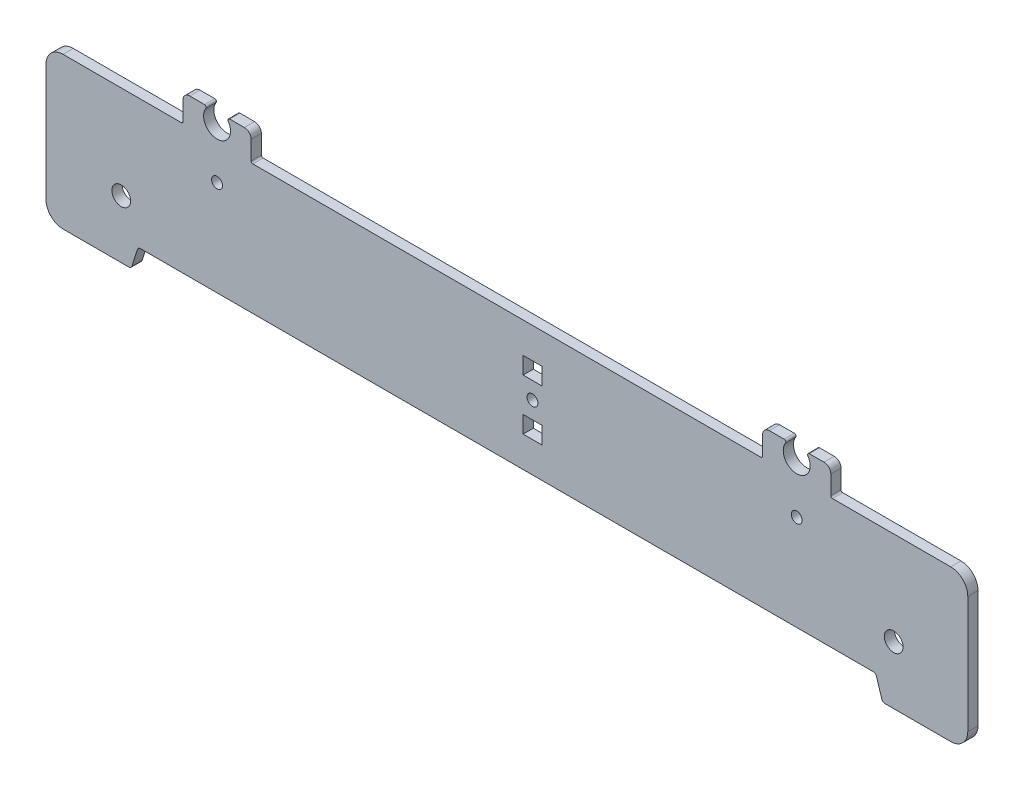
from build123d import *

# Parameters (mm, degrees)
MODEL_R                 = 1.6
MODEL_R_2               = 2.75
MODEL_W                 = 5.5
MODEL_H                 = 5
SALIENTE_EXTRUIR1_DEPTH = 3


with BuildPart() as part:
    # Model → Saliente-Extruir1 (new body)
    with BuildSketch(Plane.XY):
        with BuildLine():
            Line((136.131313967, 8.172644832), (28.691078747, 8.175075185))
            ThreePointArc((28.691078747, 8.175075185), (28.098964944, 7.980929542), (27.736763771, 7.473877674))
            Line((27.736763771, 7.473877674), (26.175859161, 2.488662696))
            ThreePointArc((26.175859161, 2.488662696), (25.813657989, 1.981610828), (25.221544186, 1.787465185))
            Line((25.221544186, 1.787465185), (5.956313823, 1.787465185))
            ThreePointArc((5.956313823, 1.787465185), (2.420778394, 3.251930446), (0.956311467, 6.787465185))
            Line((0.956311467, 6.787465185), (0.956311467, 41.175060185))
            ThreePointArc((0.956311467, 41.175060185), (2.420777561, 44.710594091), (5.956311467, 46.175060185))
            Line((5.956311467, 46.175060185), (10.956311467, 46.175060185))
            Line((10.956311467, 46.175060185), (40.628815467, 46.175060185))
            ThreePointArc((40.628815467, 46.175060185), (40.982368857, 46.321506794), (41.128815467, 46.675060185))
            Line((41.128815467, 46.675060185), (41.128815467, 52.173080185))
            ThreePointArc((41.128815467, 52.173080185), (41.714601904, 53.587293747), (43.128815467, 54.173080185))
            Line((43.128815467, 54.173080185), (47.444968064, 54.173080185))
            ThreePointArc((47.444968064, 54.173080185), (47.886694472, 53.907340256), (47.858883503, 53.392591309))
            ThreePointArc((47.858883503, 53.392591309), (51.128815467, 47.226729185), (54.39874743, 53.392591309))
            ThreePointArc((54.39874743, 53.392591309), (54.370936461, 53.907340256), (54.812662869, 54.173080185))
            Line((54.812662869, 54.173080185), (59.128815467, 54.173080185))
            ThreePointArc((59.128815467, 54.173080185), (60.543029029, 53.587293747), (61.128815467, 52.173080185))
            Line((61.128815467, 52.173080185), (61.128815467, 46.675057185))
            ThreePointArc((61.128815467, 46.675057185), (61.275262076, 46.321503794), (61.628815467, 46.175057185))
            Line((61.628815467, 46.175057185), (136.131313967, 46.175058685))
            Line((136.131313967, 46.175058685), (210.633812467, 46.175057185))
            ThreePointArc((210.633812467, 46.175057185), (210.987365857, 46.321503794), (211.133812467, 46.675057185))
            Line((211.133812467, 46.675057185), (211.133812467, 52.173080185))
            ThreePointArc((211.133812467, 52.173080185), (211.719598904, 53.587293747), (213.133812467, 54.173080185))
            Line((213.133812467, 54.173080185), (217.449965065, 54.173080185))
            ThreePointArc((217.449965065, 54.173080185), (217.891691472, 53.907340256), (217.863880503, 53.392591309))
            ThreePointArc((217.863880503, 53.392591309), (221.133812467, 47.226729185), (224.403744431, 53.392591309))
            ThreePointArc((224.403744431, 53.392591309), (224.375933462, 53.907340256), (224.81765987, 54.173080185))
            Line((224.81765987, 54.173080185), (229.133812467, 54.173080185))
            ThreePointArc((229.133812467, 54.173080185), (230.548026029, 53.587293747), (231.133812467, 52.173080185))
            Line((231.133812467, 52.173080185), (231.133812467, 46.675060185))
            ThreePointArc((231.133812467, 46.675060185), (231.280259076, 46.321506794), (231.633812467, 46.175060185))
            Line((231.633812467, 46.175060185), (261.306316467, 46.175060185))
            Line((261.306316467, 46.175060185), (266.306316467, 46.175060185))
            ThreePointArc((266.306316467, 46.175060185), (269.841850373, 44.710594091), (271.306316467, 41.175060185))
            Line((271.306316467, 41.175060185), (271.306316467, 6.787465185))
            ThreePointArc((271.306316467, 6.787465185), (269.84184954, 3.251930446), (266.306314111, 1.787465185))
            Line((266.306314111, 1.787465185), (247.041083748, 1.787465185))
            ThreePointArc((247.041083748, 1.787465185), (246.448969945, 1.981610828), (246.086768772, 2.488662696))
            Line((246.086768772, 2.488662696), (244.525864162, 7.473877674))
            ThreePointArc((244.525864162, 7.473877674), (244.16366299, 7.980929542), (243.571549187, 8.175075185))
            Line((243.571549187, 8.175075185), (136.131313967, 8.172644832))
        make_face()
        with Locations((51.128815467, 36.176729185)):
            Circle(MODEL_R, mode=Mode.SUBTRACT)
        with Locations((221.133812467, 36.176729185)):
            Circle(MODEL_R, mode=Mode.SUBTRACT)
        with Locations((143.631313967, 27.173851758)):
            Circle(MODEL_R, mode=Mode.SUBTRACT)
        with Locations((23.017213967, 18.787465185)):
            Circle(MODEL_R_2, mode=Mode.SUBTRACT)
        with Locations((249.575379967, 18.787465185)):
            Circle(MODEL_R_2, mode=Mode.SUBTRACT)
        with Locations((143.631313967, 34.673851758)):
            Rectangle(MODEL_W, MODEL_H, mode=Mode.SUBTRACT)
        with Locations((143.631313967, 19.673851758)):
            Rectangle(MODEL_W, MODEL_H, mode=Mode.SUBTRACT)
    extrude(amount=SALIENTE_EXTRUIR1_DEPTH)


solid = part.part
